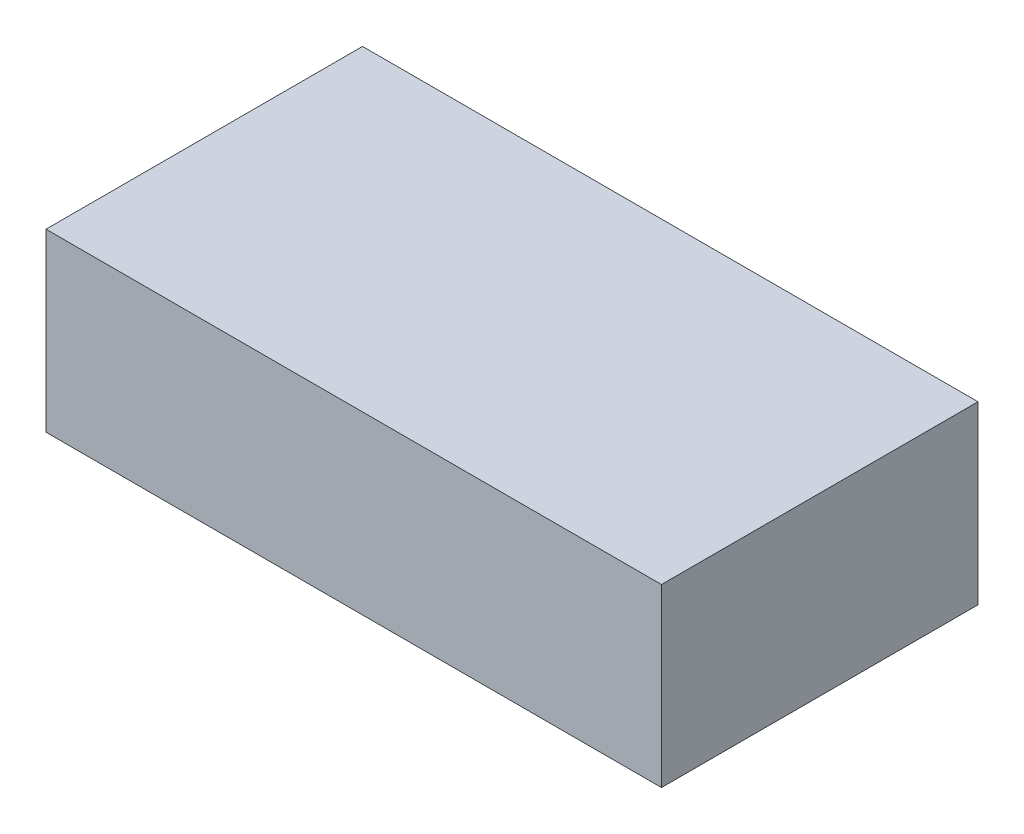
from build123d import *

# Parameters (mm, degrees)
SKETCH1_W           = 35
SKETCH1_H           = 18
BOSS_EXTRUDE1_DEPTH = 10


with BuildPart() as part:
    # Sketch1 → Boss-Extrude1 (new body)
    with BuildSketch(Plane(origin=(0, 0, 0), x_dir=(1, 0, 0), z_dir=(0, 1, 0))):
        Rectangle(SKETCH1_W, SKETCH1_H)
    extrude(amount=BOSS_EXTRUDE1_DEPTH)


solid = part.part
